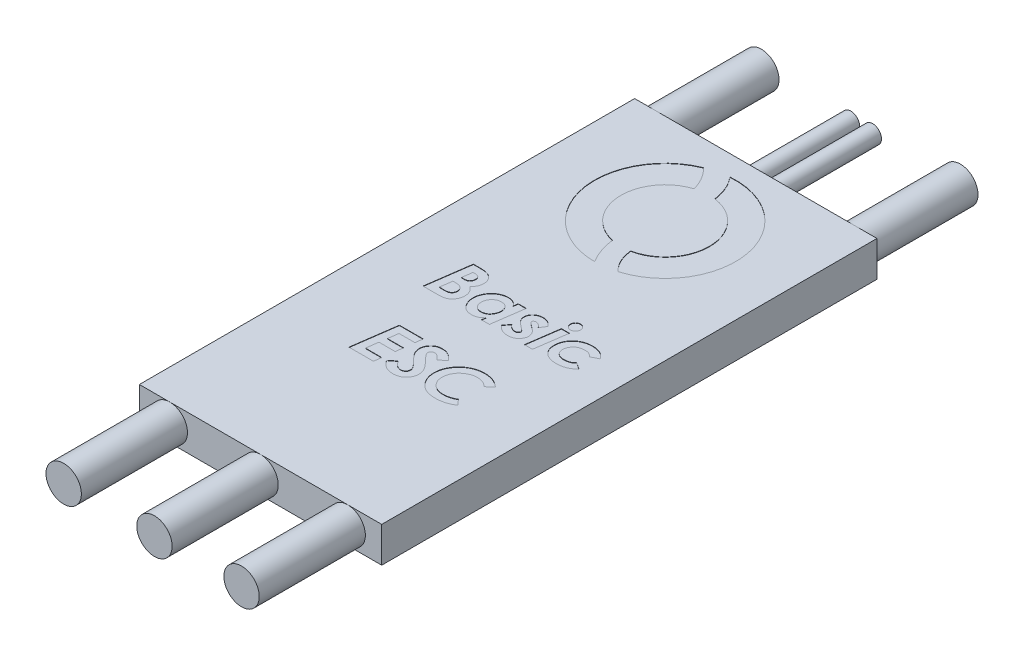
from build123d import *

# Parameters (mm, degrees)
SKETCH1_W           = 17.399
SKETCH1_H           = 35.56
BOSS_EXTRUDE1_DEPTH = 2.54
SKETCH3_R           = 1.27
BOSS_EXTRUDE2_DEPTH = 7.62
SKETCH4_R           = 1.27
SKETCH4_R_2         = 0.635
BOSS_EXTRUDE3_DEPTH = 7.62
CUT_EXTRUDE1_DEPTH  = 0.0254


with BuildPart() as part:
    # Sketch1 → Boss-Extrude1 (new body)
    with BuildSketch(Plane(origin=(0, 0, 0), x_dir=(1, 0, 0), z_dir=(0, 1, 0))):
        Rectangle(SKETCH1_W, SKETCH1_H)
    extrude(amount=BOSS_EXTRUDE1_DEPTH)

    # Sketch3 → Boss-Extrude2 (add)
    with BuildSketch(Plane.XY.offset(17.78)):
        with Locations((6.255109181, 1.27)):
            Circle(SKETCH3_R)
        with Locations((0, 1.27)):
            Circle(SKETCH3_R)
        with Locations((-6.516282842, 1.27)):
            Circle(SKETCH3_R)
    extrude(amount=BOSS_EXTRUDE2_DEPTH)

    # Sketch4 → Boss-Extrude3 (add)
    with BuildSketch(Plane(origin=(0, 0, -17.78), x_dir=(-1, 0, 0), z_dir=(0, 0, -1))):
        with Locations((-7.06474753, 1.27)):
            Circle(SKETCH4_R)
        with Locations((7.221451727, 1.27)):
            Circle(SKETCH4_R)
        with Locations((-0.7704623, 1.27)):
            Circle(SKETCH4_R_2)
        with Locations((0.796579666, 1.27)):
            Circle(SKETCH4_R_2)
    extrude(amount=BOSS_EXTRUDE3_DEPTH)

    # Sketch5 → Cut-Extrude1 (cut)
    with BuildSketch(Plane(origin=(0, 2.54, 0), x_dir=(1, 0, 0), z_dir=(0, 1, 0))):
        with BuildLine():
            ThreePointArc((-1.930262758, 15.958331611), (-4.972513144, 10.287496282), (0, 6.202429113))
            add(Edge.make_bspline(
                [(-0.682997032, 8.170306612), (-0.550095048, 7.097542795), (0, 6.202429113)],
                knots=[0, 0, 0, 1, 1, 1], degree=2))
            ThreePointArc((-0.682997032, 8.170306612), (-3.172394035, 11.134252309), (-0.947954093, 14.301891568))
            add(Edge.make_bspline(
                [(-0.947954093, 14.301891568), (-1.223539997, 15.280459102), (-1.930262758, 15.958331611)],
                knots=[0, 0, 0, 1, 1, 1], degree=2))
        make_face()
        with BuildLine():
            ThreePointArc((1.465789451, 6.418988231), (4.981301602, 12.209667954), (-0.400104359, 16.324430064))
            add(Edge.make_bspline(
                [(0.419666663, 14.418837264), (0.275384504, 15.512731783), (-0.400104359, 16.324430064)],
                knots=[0, 0, 0, 1, 1, 1], degree=2))
            ThreePointArc((0.419666663, 14.418837264), (3.173459292, 11.381029253), (0.635994732, 8.160326697))
            add(Edge.make_bspline(
                [(0.635994732, 8.160326697), (0.742806681, 7.107554171), (1.465789451, 6.418988231)],
                knots=[0, 0, 0, 1, 1, 1], degree=2))
        make_face()
        with BuildLine():
            Line((-4.191650231, 1.696110257), (-3.715909045, 1.696110257))
            add(Edge.make_bspline(
                [(-3.715909045, 1.696110257), (-3.680920246, 1.696002712), (-3.613233603, 1.695794664), (-3.515246409, 1.69034284), (-3.424050941, 1.682735104), (-3.339636315, 1.673254904), (-3.2624707, 1.658915334), (-3.192076367, 1.64262438), (-3.128537417, 1.623333542), (-3.053901465, 1.592654351), (-2.969609464, 1.545881991), (-2.87755038, 1.477558361), (-2.798065989, 1.393296148), (-2.728423479, 1.298682725), (-2.671813002, 1.19505137), (-2.631692255, 1.085259281), (-2.606383806, 0.971560678), (-2.603205766, 0.894221921), (-2.601606161, 0.855294952)],
                knots=[0, 0, 0, 0, 0.000104951, 0.000203029, 0.0002943, 0.0003795, 0.00045772, 0.000529609, 0.000596197, 0.000656669, 0.000771387, 0.000884471, 0.000999175, 0.001117481, 0.001236158, 0.001352063, 0.001467203, 0.001583888, 0.001583888, 0.001583888, 0.001583888], degree=3))
            add(Edge.make_bspline(
                [(-2.601606161, 0.855294952), (-2.602794712, 0.822586659), (-2.605147313, 0.757844327), (-2.621310981, 0.662078095), (-2.649055674, 0.56936457), (-2.686879231, 0.479980044), (-2.735330961, 0.395799957), (-2.793680735, 0.318131977), (-2.861973489, 0.247672887), (-2.913808753, 0.207243306), (-2.939967539, 0.186840425)],
                knots=[0, 0, 0, 0, 9.8114e-05, 0.000194205, 0.000290397, 0.000387858, 0.000484733, 0.000581026, 0.000678627, 0.000778062, 0.000778062, 0.000778062, 0.000778062], degree=3))
            add(Edge.make_bspline(
                [(-2.939967539, 0.186840425), (-2.906479496, 0.16194503), (-2.841077261, 0.113324258), (-2.755572902, 0.029199834), (-2.683018939, -0.060423954), (-2.622795494, -0.155946996), (-2.577129903, -0.258509302), (-2.543820899, -0.366709164), (-2.523505642, -0.481063707), (-2.521314171, -0.559336313), (-2.520195904, -0.599277363)],
                knots=[0, 0, 0, 0, 0.000125064, 0.000244251, 0.00035868, 0.000470391, 0.000581982, 0.000694442, 0.000809358, 0.000929098, 0.000929098, 0.000929098, 0.000929098], degree=3))
            add(Edge.make_bspline(
                [(-2.520195904, -0.599277363), (-2.521755306, -0.640952893), (-2.524838955, -0.723364479), (-2.550370265, -0.844112007), (-2.592844044, -0.959245272), (-2.651446416, -1.066881551), (-2.720961883, -1.165449612), (-2.800678115, -1.250887284), (-2.887670403, -1.322885197), (-2.967363247, -1.371898588), (-3.036793176, -1.403143887), (-3.094272269, -1.423363997), (-3.157154856, -1.440705996), (-3.225693431, -1.454110091), (-3.299443908, -1.466011712), (-3.378723181, -1.472950574), (-3.463328678, -1.478612371), (-3.521700361, -1.478795342), (-3.551816497, -1.478889743)],
                knots=[0, 0, 0, 0, 0.000124933, 0.00024705, 0.00036839, 0.00049189, 0.000613662, 0.000729314, 0.000841369, 0.000951538, 0.001008755, 0.001069507, 0.001134159, 0.00120426, 0.001278921, 0.001358155, 0.001442898, 0.001533222, 0.001533222, 0.001533222, 0.001533222], degree=3))
            Line((-3.551816497, -1.478889743), (-4.636862571, -1.478889743))
            Line((-4.636862571, -1.478889743), (-4.191650231, 1.696110257))
        make_face()
        with BuildLine():
            Line((-3.794775231, 0.434251282), (-3.69046834, 0.434251282))
            add(Edge.make_bspline(
                [(-3.69046834, 0.434251282), (-3.671596316, 0.434335125), (-3.635537937, 0.434495321), (-3.584032851, 0.436731474), (-3.537088123, 0.438720843), (-3.495149869, 0.443473814), (-3.457511763, 0.448277462), (-3.424911853, 0.454795759), (-3.396492558, 0.46110227), (-3.365589054, 0.473608322), (-3.330356752, 0.492230411), (-3.293286453, 0.524001342), (-3.258681309, 0.562215431), (-3.228606324, 0.608031415), (-3.203308203, 0.658979397), (-3.184878004, 0.71373007), (-3.173700649, 0.771313827), (-3.172228367, 0.810511511), (-3.171477956, 0.830490265)],
                knots=[0, 0, 0, 0, 5.6609e-05, 0.000108162, 0.000154661, 0.000197506, 0.000234744, 0.000268423, 0.000297269, 0.000321836, 0.000368231, 0.000416114, 0.000467454, 0.000522491, 0.000579948, 0.000637671, 0.0006953, 0.000755208, 0.000755208, 0.000755208, 0.000755208], degree=3))
            add(Edge.make_bspline(
                [(-3.171477956, 0.830490265), (-3.172073391, 0.848762098), (-3.173238217, 0.884506544), (-3.182712597, 0.935959213), (-3.198942219, 0.983466689), (-3.221095628, 1.026493956), (-3.248151162, 1.06457035), (-3.279658062, 1.096638767), (-3.315987472, 1.120951624), (-3.349796084, 1.136297213), (-3.38085142, 1.145503403), (-3.409663978, 1.150860161), (-3.443601875, 1.155962286), (-3.48283478, 1.160402718), (-3.52739529, 1.163492314), (-3.577247162, 1.165178224), (-3.632372284, 1.166489312), (-3.67096291, 1.166787801), (-3.691104358, 1.16694359)],
                knots=[0, 0, 0, 0, 5.479e-05, 0.000107183, 0.00015626, 0.000204902, 0.000251851, 0.000295924, 0.000338967, 0.000382235, 0.000406786, 0.000435974, 0.000470064, 0.000509748, 0.000554383, 0.000604029, 0.000659377, 0.000719802, 0.000719802, 0.000719802, 0.000719802], degree=3))
            Line((-3.691104358, 1.16694359), (-3.794775231, 0.434251282))
        make_face(mode=Mode.SUBTRACT)
        with BuildLine():
            Line((-3.987488573, -0.949723077), (-3.619870384, -0.962443429))
            add(Edge.make_bspline(
                [(-3.619870384, -0.962443429), (-3.597598895, -0.962058847), (-3.554480045, -0.961314274), (-3.492048741, -0.956127785), (-3.434168583, -0.948211997), (-3.381073129, -0.936351286), (-3.333224619, -0.92006767), (-3.289429793, -0.901941118), (-3.250323532, -0.879777467), (-3.216310307, -0.853168757), (-3.186571536, -0.824046223), (-3.160491761, -0.792421196), (-3.139161912, -0.758006548), (-3.120865877, -0.721289868), (-3.107221543, -0.681896446), (-3.096667473, -0.640034993), (-3.091188014, -0.595608552), (-3.090445421, -0.565157147), (-3.090067699, -0.549667988)],
                knots=[0, 0, 0, 0, 6.6809e-05, 0.000129346, 0.000187811, 0.000241966, 0.000292248, 0.000339266, 0.000383996, 0.000426614, 0.000468441, 0.000508671, 0.000549257, 0.000589648, 0.00063149, 0.000674065, 0.000718953, 0.000765421, 0.000765421, 0.000765421, 0.000765421], degree=3))
            add(Edge.make_bspline(
                [(-3.090067699, -0.549667988), (-3.091118451, -0.526708133), (-3.093172144, -0.481833127), (-3.107246723, -0.416068926), (-3.13268896, -0.354842037), (-3.166286829, -0.297502503), (-3.207831797, -0.246120359), (-3.257222219, -0.202718288), (-3.312882341, -0.167671109), (-3.364813892, -0.145033465), (-3.412045097, -0.130494916), (-3.455646569, -0.122345617), (-3.506228416, -0.113674276), (-3.564495607, -0.108002799), (-3.629737053, -0.101834671), (-3.702527954, -0.098460899), (-3.782672298, -0.095818764), (-3.83865772, -0.095225461), (-3.867917259, -0.094915384)],
                knots=[0, 0, 0, 0, 6.8878e-05, 0.000134622, 0.000200526, 0.000266956, 0.00033341, 0.000397848, 0.000463312, 0.000529957, 0.000567179, 0.000611336, 0.000662885, 0.000721111, 0.00078687, 0.000859476, 0.000939655, 0.001027435, 0.001027435, 0.001027435, 0.001027435], degree=3))
            Line((-3.867917259, -0.094915384), (-3.987488573, -0.949723077))
        make_face(mode=Mode.SUBTRACT)
        with BuildLine():
            Line((-0.114777234, 0.841302564), (0.460182701, 0.841302564))
            Line((0.460182701, 0.841302564), (0.13072557, -1.478889743))
            Line((0.13072557, -1.478889743), (-0.444234366, -1.478889743))
            Line((-0.444234366, -1.478889743), (-0.404165255, -1.195225881))
            add(Edge.make_bspline(
                [(-0.404165255, -1.195225881), (-0.434061628, -1.223683164), (-0.491068708, -1.277946155), (-0.579362547, -1.348343434), (-0.664355708, -1.4055961), (-0.748149382, -1.449508154), (-0.833045148, -1.481367059), (-0.921167216, -1.503433547), (-1.014307434, -1.517234309), (-1.07808243, -1.518794789), (-1.11078084, -1.519594871)],
                knots=[0, 0, 0, 0, 0.000123775, 0.000236018, 0.000338329, 0.000430782, 0.000519143, 0.000609692, 0.000702877, 0.000800925, 0.000800925, 0.000800925, 0.000800925], degree=3))
            add(Edge.make_bspline(
                [(-1.11078084, -1.519594871), (-1.148155872, -1.518724169), (-1.2213529, -1.517018944), (-1.32812716, -1.500517364), (-1.429066891, -1.474709245), (-1.524219627, -1.4382932), (-1.613071226, -1.390759916), (-1.696472349, -1.333138191), (-1.773668808, -1.264718693), (-1.843601886, -1.186406438), (-1.906670829, -1.102000784), (-1.961528093, -1.01280868), (-2.00916168, -0.920916947), (-2.046237067, -0.824646819), (-2.076842435, -0.725798742), (-2.09733081, -0.623054373), (-2.1105473, -0.5171514), (-2.112272148, -0.445401231), (-2.113144622, -0.409108093)],
                knots=[0, 0, 0, 0, 0.000112055, 0.000219453, 0.000323272, 0.000424143, 0.000524297, 0.00062486, 0.000727592, 0.000832968, 0.00093931, 0.001043269, 0.001146808, 0.001249325, 0.00135234, 0.001456868, 0.00156321, 0.00167206, 0.00167206, 0.00167206, 0.00167206], degree=3))
            add(Edge.make_bspline(
                [(-2.113144622, -0.409108093), (-2.112706848, -0.381102918), (-2.111835981, -0.325392046), (-2.1032347, -0.242292877), (-2.089219978, -0.160325305), (-2.069971903, -0.07921733), (-2.04597941, 0.001008808), (-2.015987147, 0.080064782), (-1.980010614, 0.15779141), (-1.939571313, 0.234281734), (-1.894934935, 0.308613209), (-1.844862913, 0.37837976), (-1.792300851, 0.444856418), (-1.735562746, 0.506739756), (-1.674791594, 0.563827753), (-1.611240131, 0.617920577), (-1.542861972, 0.666397572), (-1.47206492, 0.711790632), (-1.398437741, 0.751315535), (-1.323975788, 0.786834319), (-1.248103899, 0.815789493), (-1.171778886, 0.840300228), (-1.094335425, 0.858706638), (-1.01615165, 0.871937233), (-0.937135665, 0.880717662), (-0.884169612, 0.881577241), (-0.857645824, 0.882007693)],
                knots=[0, 0, 0, 0, 8.3993e-05, 0.000167088, 0.000250318, 0.000333316, 0.000417019, 0.00050136, 0.000586738, 0.000673799, 0.000760842, 0.000846608, 0.000931237, 0.001014964, 0.001098195, 0.001181258, 0.001265102, 0.001349443, 0.0014334, 0.001515626, 0.00159677, 0.001676827, 0.001755965, 0.001835327, 0.001914625, 0.001994168, 0.001994168, 0.001994168, 0.001994168], degree=3))
            add(Edge.make_bspline(
                [(-0.857645824, 0.882007693), (-0.822372565, 0.881002749), (-0.752843908, 0.87902186), (-0.65100902, 0.860452536), (-0.553453104, 0.83108308), (-0.460417641, 0.790355205), (-0.373045992, 0.738458883), (-0.29388956, 0.674533353), (-0.221159784, 0.601259975), (-0.181405102, 0.544500118), (-0.161206521, 0.515661539)],
                knots=[0, 0, 0, 0, 0.000105734, 0.000208417, 0.000309422, 0.00041081, 0.00051236, 0.000613279, 0.000715377, 0.000820829, 0.000820829, 0.000820829, 0.000820829], degree=3))
            Line((-0.161206521, 0.515661539), (-0.114777234, 0.841302564))
        make_face()
        with BuildLine():
            add(Edge.make_bspline(
                [(-0.982941297, -0.990428205), (-0.949786381, -0.989403434), (-0.885128108, -0.98740494), (-0.79171422, -0.969701519), (-0.704665475, -0.94182319), (-0.624113408, -0.901971058), (-0.549781003, -0.849557234), (-0.482308821, -0.784140837), (-0.421367191, -0.705776555), (-0.367922418, -0.61682535), (-0.323257026, -0.521159109), (-0.290531415, -0.42239439), (-0.269661412, -0.322426867), (-0.267318284, -0.255078952), (-0.26614943, -0.221482892)],
                knots=[0, 0, 0, 0, 9.9384e-05, 0.000193817, 0.000284125, 0.000372869, 0.000462333, 0.000555895, 0.000653738, 0.000759325, 0.000866603, 0.000969781, 0.001070939, 0.001171631, 0.001171631, 0.001171631, 0.001171631], degree=3))
            add(Edge.make_bspline(
                [(-0.26614943, -0.221482892), (-0.266684132, -0.200477111), (-0.267734938, -0.159196136), (-0.274603781, -0.098913803), (-0.286678761, -0.041808518), (-0.304004275, 0.012084443), (-0.326135016, 0.062823038), (-0.353235001, 0.110556013), (-0.384917267, 0.154949143), (-0.421333577, 0.195964512), (-0.462028905, 0.232302423), (-0.505177259, 0.265616096), (-0.552784571, 0.291775611), (-0.602543176, 0.314602964), (-0.655812815, 0.33144118), (-0.711868524, 0.34456075), (-0.771410758, 0.351229124), (-0.812051105, 0.352295506), (-0.832841137, 0.352841026)],
                knots=[0, 0, 0, 0, 6.3017e-05, 0.000123842, 0.000181724, 0.000237841, 0.000293379, 0.000347497, 0.000402209, 0.000456717, 0.000511651, 0.000565713, 0.00061983, 0.000674205, 0.000729717, 0.000787114, 0.000846676, 0.000909058, 0.000909058, 0.000909058, 0.000909058], degree=3))
            add(Edge.make_bspline(
                [(-0.832841137, 0.352841026), (-0.857051147, 0.352312568), (-0.904844848, 0.351269322), (-0.975077118, 0.340494605), (-1.042816337, 0.32440663), (-1.107406651, 0.300331701), (-1.169521986, 0.270658843), (-1.22819649, 0.233169173), (-1.284570929, 0.189728943), (-1.337448397, 0.13992574), (-1.385679238, 0.084819973), (-1.427891528, 0.025372403), (-1.463813726, -0.038077981), (-1.493084308, -0.105431961), (-1.51524572, -0.176978183), (-1.531920804, -0.251792138), (-1.541524912, -0.330839921), (-1.542680807, -0.384701599), (-1.543272827, -0.412288181)],
                knots=[0, 0, 0, 0, 7.2576e-05, 0.000143274, 0.00021269, 0.000281103, 0.000349657, 0.000418828, 0.000489561, 0.000562902, 0.000636375, 0.000708906, 0.000781247, 0.000854739, 0.000928764, 0.001005614, 0.001084424, 0.001167167, 0.001167167, 0.001167167, 0.001167167], degree=3))
            add(Edge.make_bspline(
                [(-1.543272827, -0.412288181), (-1.542728582, -0.433502738), (-1.541664266, -0.474989567), (-1.534971571, -0.53578385), (-1.521938215, -0.593148582), (-1.504823811, -0.647457365), (-1.483233533, -0.698762497), (-1.456342261, -0.746750335), (-1.424326319, -0.791510482), (-1.387646795, -0.832679128), (-1.346802984, -0.86932886), (-1.303519487, -0.902259965), (-1.256867451, -0.929525633), (-1.207483682, -0.952072127), (-1.155187327, -0.969205032), (-1.100163763, -0.981026462), (-1.042540122, -0.989111849), (-1.003110744, -0.989982723), (-0.982941297, -0.990428205)],
                knots=[0, 0, 0, 0, 6.3653e-05, 0.000124478, 0.000183116, 0.000239839, 0.000295125, 0.000349797, 0.000404509, 0.000459916, 0.000514849, 0.000568911, 0.000622796, 0.000676592, 0.000731499, 0.000787516, 0.000845264, 0.000905739, 0.000905739, 0.000905739, 0.000905739], degree=3))
        make_face(mode=Mode.SUBTRACT)
        with BuildLine():
            Line((2.356151251, 0.497217028), (2.085843759, 0.060908935))
            add(Edge.make_bspline(
                [(2.085843759, 0.060908935), (2.068633511, 0.08452997), (2.035502541, 0.130002169), (1.981393637, 0.190917126), (1.925438161, 0.241424554), (1.868425979, 0.281839669), (1.812130551, 0.312868938), (1.757479788, 0.335796247), (1.704320958, 0.350030248), (1.669117959, 0.351924304), (1.652079737, 0.352841026)],
                knots=[0, 0, 0, 0, 8.7644e-05, 0.00016872, 0.000243935, 0.000313287, 0.000377904, 0.00043637, 0.000490822, 0.000541898, 0.000541898, 0.000541898, 0.000541898], degree=3))
            add(Edge.make_bspline(
                [(1.652079737, 0.352841026), (1.639746983, 0.352363253), (1.615679787, 0.351430885), (1.58091536, 0.343842715), (1.549282383, 0.330278923), (1.52191632, 0.311952136), (1.498589653, 0.291310385), (1.482034914, 0.268198249), (1.470489286, 0.24381778), (1.469434202, 0.226609452), (1.46890666, 0.218005289)],
                knots=[0, 0, 0, 0, 3.6977e-05, 7.2159e-05, 0.000106066, 0.000139582, 0.000170643, 0.000198887, 0.000224525, 0.000250164, 0.000250164, 0.000250164, 0.000250164], degree=3))
            add(Edge.make_bspline(
                [(1.46890666, 0.218005289), (1.469342525, 0.209654867), (1.470235434, 0.192548261), (1.479704169, 0.167527231), (1.491852798, 0.141622326), (1.504366761, 0.126188302), (1.510883823, 0.118150521)],
                knots=[0, 0, 0, 0, 2.4935e-05, 5.1081e-05, 7.9525e-05, 0.000110436, 0.000110436, 0.000110436, 0.000110436], degree=3))
            add(Edge.make_bspline(
                [(1.510883823, 0.118150521), (1.515042885, 0.113407154), (1.524546921, 0.102567898), (1.542854246, 0.086258673), (1.565736679, 0.06653294), (1.593583076, 0.043641807), (1.626885456, 0.018553562), (1.664299796, -0.010574553), (1.707782472, -0.041358425), (1.738370958, -0.063109109), (1.754478575, -0.07456282)],
                knots=[0, 0, 0, 0, 1.891e-05, 4.3212e-05, 7.3428e-05, 0.000109586, 0.000151312, 0.000198506, 0.000251814, 0.000311111, 0.000311111, 0.000311111, 0.000311111], degree=3))
            add(Edge.make_bspline(
                [(1.754478575, -0.07456282), (1.780452221, -0.093069413), (1.830565951, -0.128776161), (1.901250681, -0.182813395), (1.964681088, -0.235012217), (2.021965395, -0.284400139), (2.071187343, -0.333029948), (2.114980647, -0.378272178), (2.150747047, -0.422594996), (2.189599091, -0.47773273), (2.226515279, -0.54830796), (2.259833303, -0.635414371), (2.279363991, -0.726679589), (2.281788054, -0.788720915), (2.283009224, -0.81997548)],
                knots=[0, 0, 0, 0, 9.5674e-05, 0.000184593, 0.000266844, 0.000342112, 0.000411377, 0.000474365, 0.000530885, 0.000582051, 0.000676519, 0.000768899, 0.000861207, 0.000954918, 0.000954918, 0.000954918, 0.000954918], degree=3))
            add(Edge.make_bspline(
                [(2.283009224, -0.81997548), (2.282454298, -0.840796538), (2.28134341, -0.88247754), (2.270558184, -0.944254376), (2.254136274, -1.005320186), (2.230149029, -1.065210092), (2.200195199, -1.124747176), (2.163119192, -1.18314739), (2.119398095, -1.240674369), (2.069977779, -1.296959512), (2.013487226, -1.348999558), (1.951112466, -1.395245832), (1.882011882, -1.433398086), (1.807429426, -1.465655887), (1.726082929, -1.489161935), (1.639408016, -1.507340813), (1.546513877, -1.517199007), (1.482708002, -1.518780078), (1.449826131, -1.519594871)],
                knots=[0, 0, 0, 0, 6.2411e-05, 0.000124938, 0.000187582, 0.000251832, 0.000318106, 0.000387277, 0.000459021, 0.000534709, 0.000611678, 0.000689022, 0.000767045, 0.000847969, 0.000932282, 0.001020594, 0.001113376, 0.001212033, 0.001212033, 0.001212033, 0.001212033], degree=3))
            add(Edge.make_bspline(
                [(1.449826131, -1.519594871), (1.411605439, -1.51851237), (1.336461635, -1.516384119), (1.226421962, -1.499089574), (1.12192642, -1.469232998), (1.038164932, -1.435851837), (0.972795974, -1.40212164), (0.92318291, -1.370925033), (0.871483006, -1.336192922), (0.818939279, -1.295876939), (0.764619154, -1.251134909), (0.708950436, -1.201796582), (0.652052355, -1.14731697), (0.614412616, -1.108837693), (0.595018439, -1.089010937)],
                knots=[0, 0, 0, 0, 0.000114626, 0.000225361, 0.000333081, 0.000440085, 0.000495272, 0.000553523, 0.000615794, 0.000682068, 0.000752102, 0.000826893, 0.000905167, 0.000988369, 0.000988369, 0.000988369, 0.000988369], degree=3))
            Line((0.595018439, -1.089010937), (0.945464152, -0.685775761))
            add(Edge.make_bspline(
                [(0.945464152, -0.685775761), (0.9652431, -0.70983629), (1.003592118, -0.756486781), (1.065172815, -0.819026879), (1.128445718, -0.87170618), (1.193251061, -0.914798046), (1.259199821, -0.948973441), (1.327134398, -0.972538663), (1.396106344, -0.988202309), (1.442957956, -0.989686687), (1.466362589, -0.990428205)],
                knots=[0, 0, 0, 0, 9.3408e-05, 0.000181107, 0.000262867, 0.000339954, 0.000414194, 0.000485, 0.000555231, 0.000625334, 0.000625334, 0.000625334, 0.000625334], degree=3))
            add(Edge.make_bspline(
                [(1.466362589, -0.990428205), (1.484231598, -0.989949657), (1.518385269, -0.989034993), (1.566646619, -0.978533381), (1.60961643, -0.962266475), (1.64582915, -0.938562332), (1.675108234, -0.910543081), (1.697628017, -0.880162542), (1.710415834, -0.845922322), (1.712219323, -0.822406482), (1.713137429, -0.810435216)],
                knots=[0, 0, 0, 0, 5.352e-05, 0.000102295, 0.000147412, 0.000190633, 0.000231119, 0.00026853, 0.000303145, 0.000339039, 0.000339039, 0.000339039, 0.000339039], degree=3))
            add(Edge.make_bspline(
                [(1.713137429, -0.810435216), (1.712502674, -0.800603623), (1.711191121, -0.780289264), (1.700639048, -0.750158343), (1.685529296, -0.719116394), (1.666314463, -0.693781665), (1.646664859, -0.671509083), (1.625859246, -0.651730824), (1.599773367, -0.629066685), (1.568577803, -0.603011878), (1.532192966, -0.573644297), (1.490355478, -0.541210255), (1.442495806, -0.506505445), (1.40891267, -0.48224442), (1.391312509, -0.469529767)],
                knots=[0, 0, 0, 0, 2.9429e-05, 6.0807e-05, 9.494e-05, 0.000132723, 0.000155699, 0.000184035, 0.000218738, 0.000259373, 0.000305959, 0.000359008, 0.000418161, 0.0004833, 0.0004833, 0.0004833, 0.0004833], degree=3))
            add(Edge.make_bspline(
                [(1.391312509, -0.469529767), (1.370686009, -0.454562148), (1.330600131, -0.425473832), (1.273601317, -0.381985178), (1.221978492, -0.339588068), (1.174627276, -0.299842025), (1.13281578, -0.261005101), (1.095601591, -0.224158754), (1.063702888, -0.188707188), (1.045188572, -0.164771896), (1.036414673, -0.153429006)],
                knots=[0, 0, 0, 0, 7.6455e-05, 0.000148583, 0.000215037, 0.000276849, 0.000334009, 0.000386178, 0.000433926, 0.000476936, 0.000476936, 0.000476936, 0.000476936], degree=3))
            add(Edge.make_bspline(
                [(1.036414673, -0.153429006), (1.015515212, -0.122832276), (0.974779919, -0.063195965), (0.93114475, 0.034033586), (0.904466568, 0.134114197), (0.900843684, 0.201946663), (0.899034865, 0.235813782)],
                knots=[0, 0, 0, 0, 0.000110976, 0.000216303, 0.000318116, 0.000419634, 0.000419634, 0.000419634, 0.000419634], degree=3))
            add(Edge.make_bspline(
                [(0.899034865, 0.235813782), (0.899503327, 0.259184337), (0.900424313, 0.305130333), (0.911892663, 0.372002536), (0.928779095, 0.43572143), (0.953383812, 0.495704472), (0.983835966, 0.553104275), (1.022576423, 0.60636925), (1.06711623, 0.657073326), (1.118686967, 0.703150142), (1.17495187, 0.744296792), (1.23342503, 0.782052857), (1.295672161, 0.812193793), (1.35977373, 0.83781595), (1.426388943, 0.857726177), (1.495611009, 0.871430796), (1.567226878, 0.880921328), (1.616007309, 0.881643263), (1.640631419, 0.882007693)],
                knots=[0, 0, 0, 0, 7.0034e-05, 0.000137686, 0.000202951, 0.000267437, 0.00033175, 0.000397405, 0.000464537, 0.00053389, 0.000604361, 0.000673533, 0.000742367, 0.000811459, 0.000880481, 0.000950581, 0.001023001, 0.001096822, 0.001096822, 0.001096822, 0.001096822], degree=3))
            add(Edge.make_bspline(
                [(1.640631419, 0.882007693), (1.675260577, 0.880713595), (1.744370547, 0.878130944), (1.846722268, 0.859456789), (1.945993032, 0.82698415), (2.041870538, 0.783179331), (2.132884828, 0.728272854), (2.21586194, 0.661207366), (2.291968073, 0.584907633), (2.334609777, 0.52664818), (2.356151251, 0.497217028)],
                knots=[0, 0, 0, 0, 0.000103866, 0.000207287, 0.000310872, 0.000416462, 0.000522922, 0.000628807, 0.000735847, 0.000845126, 0.000845126, 0.000845126, 0.000845126], degree=3))
        make_face()
        with BuildLine():
            add(Edge.make_bspline(
                [(3.382047685, 1.818225641), (3.406335967, 1.816809338), (3.454045282, 1.814027304), (3.523230404, 1.794041111), (3.585687309, 1.758293062), (3.641902441, 1.711734243), (3.68846126, 1.655519111), (3.724209309, 1.593062206), (3.744195502, 1.523877085), (3.746977536, 1.476167769), (3.748393839, 1.451879488)],
                knots=[0, 0, 0, 0, 7.2843e-05, 0.000143085, 0.000213694, 0.00028731, 0.000360926, 0.000431536, 0.000501777, 0.00057462, 0.00057462, 0.00057462, 0.00057462], degree=3))
            add(Edge.make_bspline(
                [(3.748393839, 1.451879488), (3.746987193, 1.427585718), (3.744224128, 1.379865622), (3.724046922, 1.310579347), (3.688680875, 1.247682947), (3.641847982, 1.191455125), (3.585879421, 1.144699841), (3.523035516, 1.109859234), (3.454070167, 1.089687321), (3.406344362, 1.086934675), (3.382047685, 1.085533334)],
                knots=[0, 0, 0, 0, 7.2843e-05, 0.000143085, 0.00021425, 0.000287866, 0.000361483, 0.000431785, 0.000502027, 0.000574869, 0.000574869, 0.000574869, 0.000574869], degree=3))
            add(Edge.make_bspline(
                [(3.382047685, 1.085533334), (3.357745648, 1.08692509), (3.310009312, 1.089658909), (3.240940406, 1.110021387), (3.177661113, 1.144480418), (3.121677051, 1.191508853), (3.074648616, 1.247492915), (3.040189585, 1.310772208), (3.019827106, 1.379841114), (3.017093288, 1.42757745), (3.015701532, 1.451879488)],
                knots=[0, 0, 0, 0, 7.2843e-05, 0.000143085, 0.000213946, 0.000287562, 0.000361178, 0.000432039, 0.000502281, 0.000575123, 0.000575123, 0.000575123, 0.000575123], degree=3))
            add(Edge.make_bspline(
                [(3.015701532, 1.451879488), (3.017102873, 1.476176164), (3.019855519, 1.523901969), (3.040027432, 1.592867318), (3.074868038, 1.655711223), (3.121623323, 1.711679784), (3.177851145, 1.758512677), (3.240747545, 1.793878724), (3.31003382, 1.81405593), (3.357753915, 1.816818995), (3.382047685, 1.818225641)],
                knots=[0, 0, 0, 0, 7.2843e-05, 0.000143085, 0.000213387, 0.000287003, 0.000360619, 0.000431785, 0.000502027, 0.000574869, 0.000574869, 0.000574869, 0.000574869], degree=3))
        make_face()
        Polygon((2.978812509, 0.841302564), (3.553772445, 0.841302564), (3.224315314, -1.478889743), (2.649355378, -1.478889743), align=None)
        with BuildLine():
            Line((6.251759224, 0.355385096), (5.744217157, 0.099069992))
            add(Edge.make_bspline(
                [(5.744217157, 0.099069992), (5.72604375, 0.119481743), (5.690142483, 0.159804821), (5.628421248, 0.211290978), (5.562429732, 0.254904247), (5.491838022, 0.290820054), (5.41655586, 0.318960713), (5.336460528, 0.338337475), (5.252128949, 0.350961815), (5.194321008, 0.352205843), (5.164805097, 0.352841026)],
                knots=[0, 0, 0, 0, 8.1896e-05, 0.000161784, 0.000240282, 0.000318789, 0.000398886, 0.000480797, 0.000565617, 0.000654105, 0.000654105, 0.000654105, 0.000654105], degree=3))
            add(Edge.make_bspline(
                [(5.164805097, 0.352841026), (5.125095499, 0.351565481), (5.047596148, 0.34907606), (4.934742047, 0.331228789), (4.828956726, 0.30063659), (4.730842777, 0.257755022), (4.64024504, 0.204731715), (4.560337169, 0.138641239), (4.488646721, 0.063101547), (4.428530154, -0.022953503), (4.379537102, -0.115191321), (4.344146589, -0.211635716), (4.32230883, -0.310819252), (4.319613106, -0.378047666), (4.318265634, -0.411652163)],
                knots=[0, 0, 0, 0, 0.000119105, 0.000232452, 0.000341745, 0.00044856, 0.000552947, 0.000655559, 0.000758595, 0.000864473, 0.000969454, 0.001071068, 0.00117186, 0.001272594, 0.001272594, 0.001272594, 0.001272594], degree=3))
            add(Edge.make_bspline(
                [(4.318265634, -0.411652163), (4.318695897, -0.432879775), (4.319542649, -0.474655462), (4.327924983, -0.535621086), (4.341857054, -0.593438897), (4.361812934, -0.647688616), (4.386600816, -0.699051602), (4.417370079, -0.747077055), (4.453940294, -0.791577143), (4.495114436, -0.833147383), (4.541862789, -0.869954024), (4.592726922, -0.902456938), (4.647757554, -0.9298708), (4.706756081, -0.952261782), (4.77003567, -0.969426297), (4.837558384, -0.981081522), (4.908935013, -0.989109695), (4.95786407, -0.989981863), (4.982904056, -0.990428205)],
                knots=[0, 0, 0, 0, 6.3653e-05, 0.000125268, 0.000184195, 0.000241739, 0.000298345, 0.000354979, 0.000412393, 0.000470859, 0.000530159, 0.0005905, 0.000651653, 0.000714258, 0.000779524, 0.000848016, 0.000919658, 0.000994751, 0.000994751, 0.000994751, 0.000994751], degree=3))
            add(Edge.make_bspline(
                [(4.982904056, -0.990428205), (5.017706928, -0.989515305), (5.085197969, -0.987744976), (5.183451171, -0.975719035), (5.275609143, -0.954854878), (5.361469133, -0.924935015), (5.441332201, -0.887121387), (5.515012177, -0.841166017), (5.582494434, -0.786313846), (5.621548901, -0.743534654), (5.641182301, -0.722028766)],
                knots=[0, 0, 0, 0, 0.000104402, 0.00020246, 0.000296421, 0.000387338, 0.000474676, 0.000560971, 0.000647294, 0.000734561, 0.000734561, 0.000734561, 0.000734561], degree=3))
            Line((5.641182301, -0.722028766), (6.112471363, -1.037493509))
            add(Edge.make_bspline(
                [(6.112471363, -1.037493509), (6.078321479, -1.073984042), (6.009834995, -1.147164623), (5.891242797, -1.241780615), (5.761606237, -1.325038595), (5.620104848, -1.394776557), (5.468687275, -1.450907147), (5.307927348, -1.49104909), (5.138586952, -1.514727288), (5.022836648, -1.517951213), (4.963823527, -1.519594871)],
                knots=[0, 0, 0, 0, 0.000149767, 0.000300353, 0.00045367, 0.000611248, 0.000772637, 0.000937229, 0.001107408, 0.001284414, 0.001284414, 0.001284414, 0.001284414], degree=3))
            add(Edge.make_bspline(
                [(4.963823527, -1.519594871), (4.917987794, -1.518859249), (4.828634601, -1.51742521), (4.698351531, -1.502814115), (4.575383296, -1.48072603), (4.460291022, -1.447629408), (4.351817468, -1.407423248), (4.251282699, -1.356382302), (4.158289472, -1.296043162), (4.073129339, -1.227536994), (3.996655483, -1.15129159), (3.930450262, -1.068286549), (3.873698095, -0.979829265), (3.827717912, -0.885012326), (3.792207493, -0.784242793), (3.766708007, -0.67769359), (3.751170347, -0.565391859), (3.749332083, -0.488448738), (3.748393839, -0.449177203)],
                knots=[0, 0, 0, 0, 0.000137452, 0.000267952, 0.00039282, 0.00051181, 0.000626746, 0.000739384, 0.00084929, 0.000958752, 0.001066688, 0.001172573, 0.00127667, 0.001381349, 0.001487965, 0.001596565, 0.00170954, 0.001827314, 0.001827314, 0.001827314, 0.001827314], degree=3))
            add(Edge.make_bspline(
                [(3.748393839, -0.449177203), (3.749560243, -0.403946972), (3.751859952, -0.314770043), (3.771761568, -0.183795296), (3.802610291, -0.057714372), (3.846840485, 0.063173843), (3.903753883, 0.178952698), (3.973641089, 0.289288887), (4.055509177, 0.394830587), (4.149306307, 0.4939635), (4.25247322, 0.585194039), (4.364873231, 0.664490721), (4.483946002, 0.7323461), (4.610765122, 0.787082856), (4.744538564, 0.829893849), (4.885514846, 0.860335959), (5.033960915, 0.878217072), (5.135287175, 0.880725742), (5.187065714, 0.882007693)],
                knots=[0, 0, 0, 0, 0.000135621, 0.000267393, 0.000396506, 0.000524474, 0.000652757, 0.000782807, 0.000915625, 0.001052853, 0.001191663, 0.001328075, 0.001464789, 0.001602086, 0.001741677, 0.001885514, 0.002034141, 0.00218946, 0.00218946, 0.00218946, 0.00218946], degree=3))
            add(Edge.make_bspline(
                [(5.187065714, 0.882007693), (5.216336425, 0.881713894), (5.274101723, 0.881134088), (5.35919201, 0.874371122), (5.441438759, 0.864618495), (5.520749403, 0.849585637), (5.597283883, 0.831527526), (5.671201213, 0.808998502), (5.742289597, 0.782541662), (5.810384311, 0.75123881), (5.87550185, 0.716027646), (5.938074262, 0.677418123), (5.997443192, 0.63383293), (6.053951429, 0.586003122), (6.108126569, 0.534603534), (6.159192782, 0.478826025), (6.207647283, 0.419294156), (6.236984501, 0.376790607), (6.251759224, 0.355385096)],
                knots=[0, 0, 0, 0, 8.7791e-05, 0.000173255, 0.000255929, 0.000336141, 0.000415278, 0.000491733, 0.000567811, 0.000642661, 0.000716365, 0.000789783, 0.000863058, 0.000937082, 0.00101176, 0.001086931, 0.001163813, 0.001241815, 0.001241815, 0.001241815, 0.001241815], degree=3))
        make_face()
        Polygon((-3.051906642, -4.758376923), (-1.339747186, -4.758376923), (-1.406529037, -5.287543589), (-2.550724751, -5.287543589), (-2.653759606, -6.020235897), (-1.498751593, -6.020235897), (-1.566169462, -6.549402564), (-2.728173669, -6.549402564), (-2.847744983, -7.404210256), (-1.673656441, -7.404210256), (-1.740438292, -7.933376923), (-3.497118981, -7.933376923), align=None)
        with BuildLine():
            Line((0.897126812, -5.199773157), (0.455730578, -5.584563822))
            add(Edge.make_bspline(
                [(0.455730578, -5.584563822), (0.433670641, -5.554764249), (0.391393179, -5.497653918), (0.324307523, -5.421053574), (0.260037, -5.354488798), (0.19529803, -5.301406249), (0.132195967, -5.25931486), (0.070180926, -5.22882472), (0.008904315, -5.209557343), (-0.031969714, -5.207252291), (-0.051811489, -5.206133333)],
                knots=[0, 0, 0, 0, 0.000111179, 0.000213073, 0.00030527, 0.000388415, 0.00046374, 0.000532294, 0.000595286, 0.000654712, 0.000654712, 0.000654712, 0.000654712], degree=3))
            add(Edge.make_bspline(
                [(-0.051811489, -5.206133333), (-0.070553741, -5.206944741), (-0.10659759, -5.208505188), (-0.158336136, -5.221808968), (-0.205359718, -5.243208918), (-0.245731346, -5.274166585), (-0.279449681, -5.309859494), (-0.304486001, -5.349913598), (-0.319066831, -5.394062047), (-0.321087944, -5.424606218), (-0.322118981, -5.44018782)],
                knots=[0, 0, 0, 0, 5.6146e-05, 0.000107977, 0.000159195, 0.000210076, 0.00025958, 0.00030583, 0.000350682, 0.000397389, 0.000397389, 0.000397389, 0.000397389], degree=3))
            add(Edge.make_bspline(
                [(-0.322118981, -5.44018782), (-0.321179993, -5.455537892), (-0.319205017, -5.487823726), (-0.304735302, -5.536768561), (-0.282847946, -5.588339419), (-0.256522142, -5.633180346), (-0.226963935, -5.673897307), (-0.195988786, -5.713738548), (-0.155543465, -5.761373649), (-0.106328337, -5.817347994), (-0.048813579, -5.88213386), (0.018492555, -5.954788605), (0.094378189, -6.035789393), (0.148278214, -6.092359249), (0.176518839, -6.121998718)],
                knots=[0, 0, 0, 0, 4.6009e-05, 9.6771e-05, 0.000152057, 0.000213908, 0.000252207, 0.000302969, 0.000365266, 0.000439637, 0.000526576, 0.00062515, 0.000736742, 0.000859559, 0.000859559, 0.000859559, 0.000859559], degree=3))
            add(Edge.make_bspline(
                [(0.176518839, -6.121998718), (0.191838655, -6.137846307), (0.221234405, -6.168254751), (0.262480537, -6.212665288), (0.299293558, -6.253825423), (0.333282631, -6.29029358), (0.362379453, -6.323952728), (0.387222648, -6.353995333), (0.408313022, -6.379998652), (0.420781871, -6.39630902), (0.426473767, -6.403754527)],
                knots=[0, 0, 0, 0, 6.6124e-05, 0.00012688, 0.000181814, 0.000231785, 0.000276419, 0.000315263, 0.000348737, 0.000376852, 0.000376852, 0.000376852, 0.000376852], degree=3))
            add(Edge.make_bspline(
                [(0.426473767, -6.403754527), (0.449139247, -6.435067164), (0.4928542, -6.495459905), (0.54955574, -6.587282591), (0.596454243, -6.67575199), (0.633307024, -6.761915128), (0.660875341, -6.846714421), (0.680842251, -6.9315516), (0.693419818, -7.017132339), (0.694814806, -7.07471137), (0.695509224, -7.103373918)],
                knots=[0, 0, 0, 0, 0.000115933, 0.000223601, 0.000323458, 0.000416074, 0.000504371, 0.000590609, 0.000677318, 0.000763265, 0.000763265, 0.000763265, 0.000763265], degree=3))
            add(Edge.make_bspline(
                [(0.695509224, -7.103373918), (0.694645101, -7.135009319), (0.692944503, -7.197267948), (0.679766959, -7.288613055), (0.659241916, -7.376198365), (0.628635964, -7.45949768), (0.590845085, -7.539417443), (0.542880427, -7.614787362), (0.487703258, -7.686882692), (0.424004383, -7.754000212), (0.354284943, -7.815378877), (0.278368181, -7.868530755), (0.198124229, -7.913835684), (0.112737363, -7.951133814), (0.02246778, -7.9795021), (-0.072523483, -7.99967953), (-0.172061071, -8.013073236), (-0.240239634, -8.014207824), (-0.275053677, -8.014787179)],
                knots=[0, 0, 0, 0, 9.4871e-05, 0.000186707, 0.000276333, 0.000364254, 0.00045244, 0.000541027, 0.00063173, 0.000724415, 0.000818171, 0.000909927, 0.001001912, 0.001094196, 0.001188937, 0.001285243, 0.001385274, 0.001489651, 0.001489651, 0.001489651, 0.001489651], degree=3))
            add(Edge.make_bspline(
                [(-0.275053677, -8.014787179), (-0.301780535, -8.014251654), (-0.354688834, -8.013191531), (-0.433108618, -8.00615285), (-0.509627003, -7.994136905), (-0.584131541, -7.976797004), (-0.656777798, -7.955145674), (-0.727679034, -7.929156966), (-0.796657841, -7.897700663), (-0.863802559, -7.861594726), (-0.929119394, -7.820697944), (-0.99221642, -7.774522498), (-1.053774414, -7.723958841), (-1.112986547, -7.668049335), (-1.171102995, -7.608337279), (-1.227105858, -7.543464292), (-1.280432407, -7.473158474), (-1.314284165, -7.424060916), (-1.331478957, -7.399122115)],
                knots=[0, 0, 0, 0, 8.0179e-05, 0.000158721, 0.000235994, 0.000312364, 0.000388026, 0.000463286, 0.000538715, 0.000615262, 0.000691849, 0.000769705, 0.000849674, 0.000930671, 0.001013883, 0.001099563, 0.001187592, 0.001278462, 0.001278462, 0.001278462, 0.001278462], degree=3))
            Line((-1.331478957, -7.399122115), (-0.86146193, -7.029595873))
            add(Edge.make_bspline(
                [(-0.86146193, -7.029595873), (-0.838051079, -7.065593066), (-0.793150554, -7.134633394), (-0.71996477, -7.227825602), (-0.645352169, -7.307028584), (-0.569041835, -7.371934388), (-0.490788261, -7.422436099), (-0.411153177, -7.458535127), (-0.329782166, -7.481753966), (-0.274566463, -7.484335101), (-0.247068901, -7.485620512)],
                knots=[0, 0, 0, 0, 0.000128773, 0.000246978, 0.000354947, 0.000454705, 0.000546802, 0.000633338, 0.000716343, 0.000798687, 0.000798687, 0.000798687, 0.000798687], degree=3))
            add(Edge.make_bspline(
                [(-0.247068901, -7.485620512), (-0.22169766, -7.48450861), (-0.172307739, -7.482344082), (-0.101655688, -7.46219083), (-0.036835109, -7.431123286), (0.019282609, -7.386763715), (0.066557854, -7.334666361), (0.100922735, -7.275316319), (0.121611235, -7.210288073), (0.124275209, -7.165217683), (0.125637429, -7.142170993)],
                knots=[0, 0, 0, 0, 7.5953e-05, 0.000147857, 0.000218683, 0.000290308, 0.000361032, 0.000428561, 0.000494541, 0.000563587, 0.000563587, 0.000563587, 0.000563587], degree=3))
            add(Edge.make_bspline(
                [(0.125637429, -7.142170993), (0.124986663, -7.123438636), (0.123662885, -7.085333569), (0.109863762, -7.028580245), (0.089383581, -6.971032631), (0.064561, -6.9223962), (0.037788237, -6.879748449), (0.009435618, -6.841127889), (-0.026240107, -6.795796387), (-0.070375994, -6.744817956), (-0.121167896, -6.686471564), (-0.180540323, -6.622807775), (-0.246596294, -6.551719765), (-0.294025062, -6.503081656), (-0.318938893, -6.477532572)],
                knots=[0, 0, 0, 0, 5.6099e-05, 0.000114117, 0.00017427, 0.000239122, 0.000277415, 0.000325252, 0.000382765, 0.000450441, 0.000527504, 0.000614826, 0.00071157, 0.000818621, 0.000818621, 0.000818621, 0.000818621], degree=3))
            add(Edge.make_bspline(
                [(-0.318938893, -6.477532572), (-0.345307656, -6.450260265), (-0.396282692, -6.397538534), (-0.468398717, -6.320380633), (-0.533358113, -6.248566239), (-0.591087329, -6.182019787), (-0.641634049, -6.120621653), (-0.685872908, -6.064837617), (-0.722464928, -6.013931804), (-0.743102601, -5.980902898), (-0.752702916, -5.965538381)],
                knots=[0, 0, 0, 0, 0.000113805, 0.000220002, 0.000316821, 0.000404296, 0.000484265, 0.000555388, 0.000617864, 0.000672205, 0.000672205, 0.000672205, 0.000672205], degree=3))
            add(Edge.make_bspline(
                [(-0.752702916, -5.965538381), (-0.774138588, -5.927252337), (-0.815727492, -5.852970803), (-0.85860257, -5.736058618), (-0.886542575, -5.620648446), (-0.890195027, -5.54358588), (-0.891990776, -5.505697636)],
                knots=[0, 0, 0, 0, 0.000131434, 0.000255005, 0.000372421, 0.000485981, 0.000485981, 0.000485981, 0.000485981], degree=3))
            add(Edge.make_bspline(
                [(-0.891990776, -5.505697636), (-0.891345982, -5.481287645), (-0.890063367, -5.432731613), (-0.880829527, -5.361069298), (-0.866691095, -5.290994522), (-0.844152103, -5.223570197), (-0.818158144, -5.157108015), (-0.784180813, -5.093354337), (-0.746007156, -5.030593984), (-0.71538161, -4.991715397), (-0.699913452, -4.972078846)],
                knots=[0, 0, 0, 0, 7.3211e-05, 0.000145631, 0.000216483, 0.000287284, 0.00035862, 0.000430307, 0.000503725, 0.000578648, 0.000578648, 0.000578648, 0.000578648], degree=3))
            add(Edge.make_bspline(
                [(-0.699913452, -4.972078846), (-0.679494145, -4.948413018), (-0.639219912, -4.901735478), (-0.569537843, -4.842068314), (-0.495655475, -4.79052946), (-0.415982448, -4.749154148), (-0.331434935, -4.716177543), (-0.241208827, -4.693800708), (-0.145995604, -4.679182017), (-0.080700648, -4.677715505), (-0.047359366, -4.676966666)],
                knots=[0, 0, 0, 0, 9.3652e-05, 0.000184716, 0.000274338, 0.000363383, 0.000453386, 0.000545941, 0.000641735, 0.000741689, 0.000741689, 0.000741689, 0.000741689], degree=3))
            add(Edge.make_bspline(
                [(-0.047359366, -4.676966666), (-0.001253476, -4.678576291), (0.08969714, -4.681751512), (0.223498992, -4.706430826), (0.351004349, -4.748264374), (0.473488413, -4.805102038), (0.588962435, -4.879953957), (0.698968609, -4.970436132), (0.803446232, -5.077193497), (0.865318149, -5.158151989), (0.897126812, -5.199773157)],
                knots=[0, 0, 0, 0, 0.000138263, 0.000272745, 0.000406497, 0.000539941, 0.000676673, 0.000818128, 0.000966551, 0.001123591, 0.001123591, 0.001123591, 0.001123591], degree=3))
        make_face()
        with BuildLine():
            Line((4.243215554, -5.157795993), (3.803727373, -5.551490905))
            add(Edge.make_bspline(
                [(3.803727373, -5.551490905), (3.779338252, -5.524768558), (3.730655898, -5.471428925), (3.64630331, -5.402932444), (3.554910058, -5.343313093), (3.456061377, -5.293816248), (3.351253649, -5.254283279), (3.241386501, -5.226427063), (3.127112162, -5.209420531), (3.049469696, -5.207241621), (3.009977373, -5.206133333)],
                knots=[0, 0, 0, 0, 0.000108409, 0.000216391, 0.000324884, 0.000435246, 0.000547353, 0.00066027, 0.000774683, 0.000893121, 0.000893121, 0.000893121, 0.000893121], degree=3))
            add(Edge.make_bspline(
                [(3.009977373, -5.206133333), (2.98197241, -5.20657215), (2.926261961, -5.207445091), (2.84315965, -5.216030934), (2.761000485, -5.230139173), (2.679650679, -5.249233774), (2.598914161, -5.273257415), (2.519673141, -5.304066894), (2.441189187, -5.339899568), (2.363829223, -5.380194549), (2.289486585, -5.42579898), (2.218722455, -5.474783563), (2.152214762, -5.526985664), (2.090302307, -5.583248416), (2.032595742, -5.643182403), (1.978048305, -5.705856191), (1.929382146, -5.773214487), (1.884050326, -5.842761422), (1.844212472, -5.915199344), (1.809396852, -5.988976389), (1.778657558, -6.063566188), (1.755981992, -6.140133342), (1.736067769, -6.217377976), (1.723299497, -6.296156972), (1.714380886, -6.375988604), (1.71355343, -6.429594007), (1.713137429, -6.45654399)],
                knots=[0, 0, 0, 0, 8.3993e-05, 0.000167088, 0.000250318, 0.000333935, 0.000417638, 0.0005028, 0.000588757, 0.00067638, 0.000764298, 0.000850219, 0.000934452, 0.001017751, 0.001100962, 0.001183952, 0.001266767, 0.001350036, 0.001432878, 0.001514529, 0.001594722, 0.00167459, 0.001753878, 0.001833867, 0.001913798, 0.001994613, 0.001994613, 0.001994613, 0.001994613], degree=3))
            add(Edge.make_bspline(
                [(1.713137429, -6.45654399), (1.713838713, -6.492642483), (1.71521849, -6.563666336), (1.730703072, -6.667718559), (1.753750201, -6.767353425), (1.787107744, -6.862239075), (1.83012783, -6.952167032), (1.881526705, -7.038200477), (1.944068977, -7.118271681), (2.014120886, -7.193858269), (2.092081785, -7.262015833), (2.175630628, -7.322522728), (2.265299449, -7.372645332), (2.359895782, -7.414531363), (2.460268081, -7.446076767), (2.565642449, -7.468846951), (2.676299118, -7.483390884), (2.751919912, -7.484866622), (2.790551291, -7.485620512)],
                knots=[0, 0, 0, 0, 0.000108215, 0.000212912, 0.000314884, 0.000414655, 0.000513943, 0.000613531, 0.000714665, 0.000818166, 0.000922273, 0.001024822, 0.001127063, 0.001229872, 0.001334668, 0.00144208, 0.001552997, 0.001668838, 0.001668838, 0.001668838, 0.001668838], degree=3))
            add(Edge.make_bspline(
                [(2.790551291, -7.485620512), (2.832131144, -7.484910997), (2.913968423, -7.483514531), (3.034459642, -7.471789043), (3.150700656, -7.452752466), (3.26260797, -7.426281484), (3.37029332, -7.391498782), (3.473783527, -7.349816372), (3.573201448, -7.300100628), (3.63568977, -7.26098076), (3.666983583, -7.241389743)],
                knots=[0, 0, 0, 0, 0.000124718, 0.000245469, 0.000362786, 0.000477869, 0.000590104, 0.000701951, 0.000812312, 0.000923025, 0.000923025, 0.000923025, 0.000923025], degree=3))
            Line((3.666983583, -7.241389743), (4.023789472, -7.634448637))
            add(Edge.make_bspline(
                [(4.023789472, -7.634448637), (3.978247109, -7.66487822), (3.887411986, -7.725570609), (3.743297148, -7.8029772), (3.593778249, -7.867954219), (3.439401881, -7.921480169), (3.27980348, -7.963790096), (3.114748479, -7.993355852), (2.944252171, -8.011767312), (2.828759607, -8.013771135), (2.770198727, -8.014787179)],
                knots=[0, 0, 0, 0, 0.000164247, 0.000327593, 0.000489946, 0.000652871, 0.000817323, 0.000984741, 0.001155489, 0.001331124, 0.001331124, 0.001331124, 0.001331124], degree=3))
            add(Edge.make_bspline(
                [(2.770198727, -8.014787179), (2.729264372, -8.014154452), (2.648782007, -8.012910426), (2.530539757, -8.003779711), (2.416856993, -7.989492572), (2.307952542, -7.968328673), (2.203613827, -7.941774095), (2.103816228, -7.909404402), (2.008954329, -7.870378902), (1.918456562, -7.826061878), (1.832805758, -7.77530447), (1.751215034, -7.719461403), (1.674294802, -7.657529188), (1.601397931, -7.590605934), (1.533198011, -7.51786688), (1.469521137, -7.43923193), (1.40980511, -7.355344409), (1.354632046, -7.266641031), (1.305092747, -7.174014731), (1.26216583, -7.078684993), (1.224565677, -6.98194924), (1.195799985, -6.882563377), (1.171855958, -6.781842022), (1.155608002, -6.67871233), (1.144907341, -6.574011136), (1.143814294, -6.503423877), (1.143265634, -6.467992307)],
                knots=[0, 0, 0, 0, 0.000122793, 0.000241426, 0.000355579, 0.000466345, 0.000574018, 0.000678404, 0.000780805, 0.000881497, 0.000980432, 0.001079225, 0.00117786, 0.001276434, 0.001375875, 0.001476697, 0.001579763, 0.001684598, 0.001789878, 0.001894626, 0.0019981, 0.002100932, 0.002204761, 0.002308486, 0.002413921, 0.002520184, 0.002520184, 0.002520184, 0.002520184], degree=3))
            add(Edge.make_bspline(
                [(1.143265634, -6.467992307), (1.143932548, -6.42979664), (1.145262343, -6.353636217), (1.158086776, -6.239985566), (1.177487599, -6.127531282), (1.205260552, -6.016278313), (1.23985895, -5.906184825), (1.283817285, -5.797718767), (1.33445057, -5.689960382), (1.393707159, -5.584528097), (1.458376513, -5.481874269), (1.530153087, -5.384817221), (1.607281329, -5.293279812), (1.689075111, -5.206400643), (1.77731479, -5.1261077), (1.871186373, -5.051563659), (1.970342538, -4.982251276), (2.074629105, -4.918730093), (2.182586326, -4.861631567), (2.293942539, -4.812682055), (2.407407036, -4.770327102), (2.523438099, -4.736069644), (2.642102491, -4.710021184), (2.762917176, -4.690903855), (2.886356585, -4.679146904), (2.969458868, -4.677696198), (3.011249408, -4.676966666)],
                knots=[0, 0, 0, 0, 0.000114547, 0.000228401, 0.00034269, 0.000456686, 0.000572144, 0.000688596, 0.000807517, 0.000929092, 0.001051189, 0.001171273, 0.0012909, 0.001410121, 0.001528973, 0.001648467, 0.001769506, 0.001891674, 0.002014577, 0.002135596, 0.002256339, 0.002377691, 0.00249821, 0.00262055, 0.002744467, 0.002869821, 0.002869821, 0.002869821, 0.002869821], degree=3))
            add(Edge.make_bspline(
                [(3.011249408, -4.676966666), (3.069621249, -4.678451872), (3.184887101, -4.68138468), (3.354644725, -4.704108455), (3.518477217, -4.741564139), (3.676162249, -4.794812856), (3.828279352, -4.862229708), (3.973820183, -4.945572936), (4.113398684, -5.043723925), (4.199572972, -5.119446589), (4.243215554, -5.157795993)],
                knots=[0, 0, 0, 0, 0.000175071, 0.00034571, 0.000512799, 0.000678528, 0.000844234, 0.001011162, 0.00118092, 0.001355113, 0.001355113, 0.001355113, 0.001355113], degree=3))
        make_face()
    extrude(amount=-CUT_EXTRUDE1_DEPTH, mode=Mode.SUBTRACT)


solid = part.part
